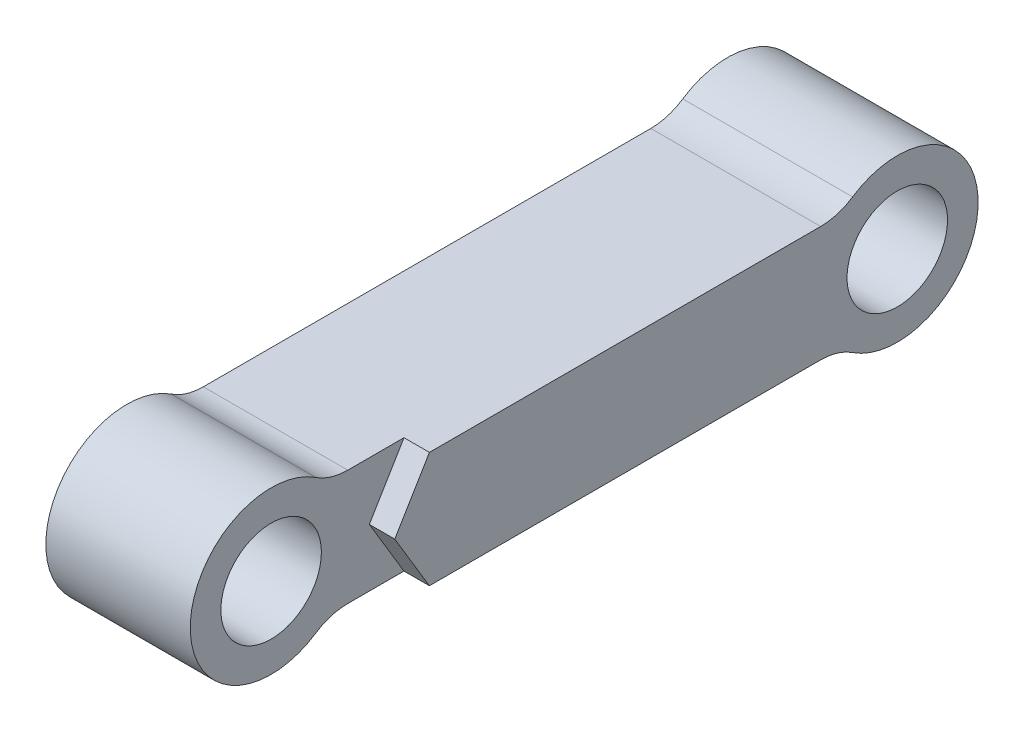
from build123d import *

# Parameters (mm, degrees)
CROQUIS1_R              = 4.35
SALIENTE_EXTRUIR1_DEPTH = 14.7
CROQUIS2_R              = 4.35
CORTAR_EXTRUIR1_DEPTH   = 2.2


with BuildPart() as part:
    # Croquis1 → Saliente-Extruir1 (new body)
    with BuildSketch(Plane(origin=(0, 0, 0), x_dir=(0, 0, -1), z_dir=(1, 0, 0))):
        with BuildLine():
            Line((19.366750419, 5), (-19.366750419, 5))
            ThreePointArc((-19.366750419, 5), (-20.810126092, 5.212864461), (-22.130604411, 5.833333333))
            ThreePointArc((-22.130604411, 5.833333333), (-33, 0), (-22.130604411, -5.833333333))
            ThreePointArc((-22.130604411, -5.833333333), (-20.810126092, -5.212864461), (-19.366750419, -5))
            Line((-19.366750419, -5), (19.366750419, -5))
            ThreePointArc((19.366750419, -5), (20.810126092, -5.212864461), (22.130604411, -5.833333333))
            ThreePointArc((22.130604411, -5.833333333), (33, 0), (22.130604411, 5.833333333))
            ThreePointArc((22.130604411, 5.833333333), (20.810126092, 5.212864461), (19.366750419, 5))
        make_face()
        with Locations((-26, 0)):
            Circle(CROQUIS1_R, mode=Mode.SUBTRACT)
        with Locations((26, 0)):
            Circle(CROQUIS1_R, mode=Mode.SUBTRACT)
    extrude(amount=SALIENTE_EXTRUIR1_DEPTH)

    # Croquis2 → Cortar-Extruir1 (cut)
    with BuildSketch(Plane(origin=(14.7, 0, 0), x_dir=(0, 0, -1), z_dir=(1, 0, 0))):
        with BuildLine():
            Line((-17.5, 0), (-14.5, 5))
            Line((-14.5, 5), (-19.366750419, 5))
            ThreePointArc((-19.366750419, 5), (-20.810126092, 5.212864461), (-22.130604411, 5.833333333))
            ThreePointArc((-22.130604411, 5.833333333), (-33, 0), (-22.130604411, -5.833333333))
            ThreePointArc((-22.130604411, -5.833333333), (-20.810126092, -5.212864461), (-19.366750419, -5))
            Line((-19.366750419, -5), (-14.5, -5))
            Line((-14.5, -5), (-17.5, 0))
        make_face()
        with Locations((-26, 0)):
            Circle(CROQUIS2_R, mode=Mode.SUBTRACT)
    extrude(amount=-CORTAR_EXTRUIR1_DEPTH, mode=Mode.SUBTRACT)


solid = part.part
